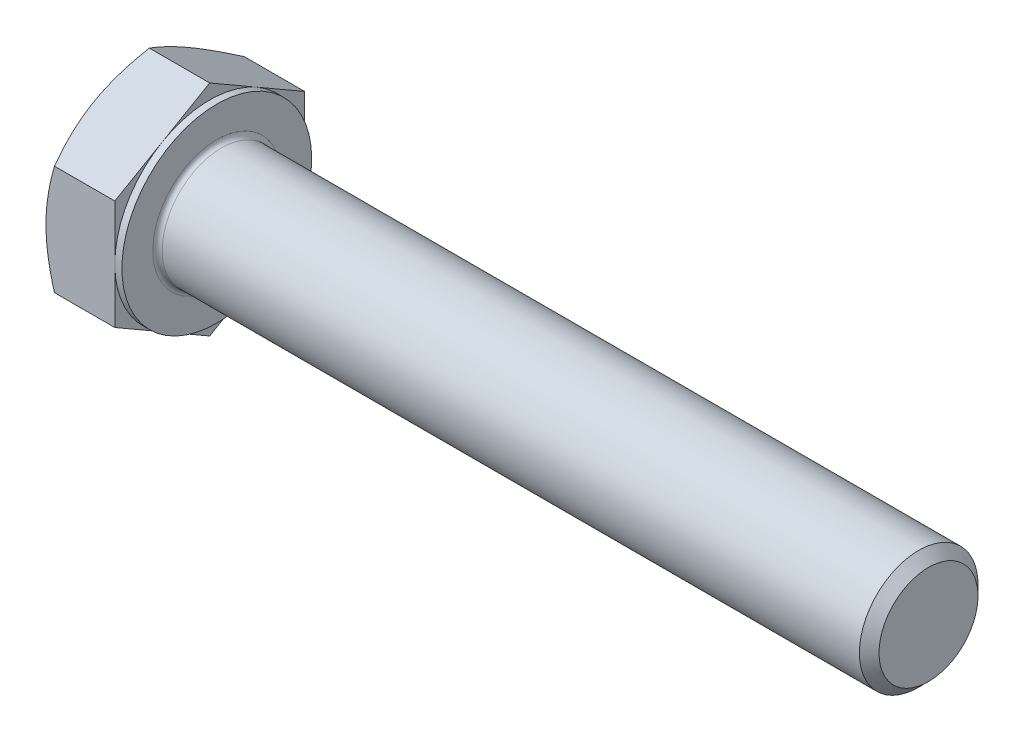
from build123d import *

# Parameters (mm, degrees)
BASEHEAD_DEPTH = 6.4
HEADFILLET_R   = 0.4
SKETCH4_W      = 0.6
SKETCH4_H      = 11.237604307


with BuildPart() as part:
    # Sketch1 → BaseHead (new body)
    with BuildSketch(Plane(origin=(0, 0, 0), x_dir=(0, 0, -1), z_dir=(1, 0, 0))):
        Polygon((8, 4.618802154), (8, -4.618802154), (0, -9.237604307), (-8, -4.618802154), (-8, 4.618802154), (0, 9.237604307), align=None)
    extrude(amount=BASEHEAD_DEPTH)

    # BodySke → BaseBody (revolve)
    with BuildSketch(Plane.XY):
        Polygon((0, 0), (66.4, 0), (66.4, 4.172), (65.572, 5), (0, 5), align=None)
    revolve(axis=Axis((0, 0, 0), (1, 0, 0)))

    # HeadFillet
    headfillet_edges = [part.edges().sort_by_distance(p)[0] for p in [
        (6.4, -5, 0),
    ]]
    fillet(headfillet_edges, radius=HEADFILLET_R)

    # Sketch3 → HeadChamfer (revolve, cut)
    with BuildSketch(Plane.XY):
        Polygon((0, 8), (3.601282526, 14.237604307), (3.601282526, 19.237604307), (-10, 19.237604307), (-10, 8), align=None)
    revolve(axis=Axis((0, 0, 0), (1, 0, 0)), mode=Mode.SUBTRACT)

    # Sketch4 → BearingFace (revolve, cut)
    with BuildSketch(Plane.XY):
        with Locations((6.1, 13.618802154)):
            Rectangle(SKETCH4_W, SKETCH4_H)
    revolve(axis=Axis((0, 0, 0), (1, 0, 0)), mode=Mode.SUBTRACT)


solid = part.part
